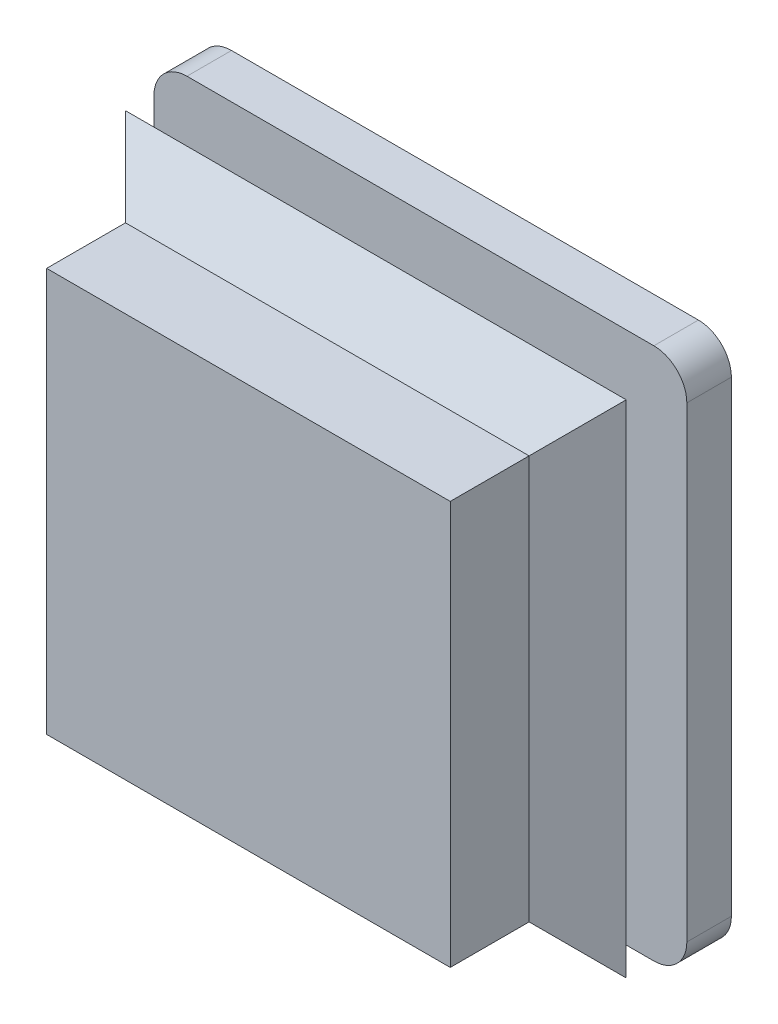
from build123d import *

# Parameters (mm, degrees)
ESQUISSE1_W        = 59.8
ESQUISSE1_H        = 59.8
BOSS_EXTRU_1_DEPTH = 5
ESQUISSE2_W        = 45.3
ESQUISSE2_H        = 45.3
BOSS_EXTRU_2_DEPTH = 24.3
CONG_1_R           = 3.7
ESQUISSE6_W        = 56.2
ESQUISSE6_H        = 56.2
BOSS_EXTRU_4_DEPTH = 10
BOSS_EXTRU_4_TAPER = 45


with BuildPart() as part:
    # Esquisse1 → Boss.-Extru.1 (new body)
    with BuildSketch(Plane.XY):
        Rectangle(ESQUISSE1_W, ESQUISSE1_H)
    extrude(amount=BOSS_EXTRU_1_DEPTH)

    # Esquisse2 → Boss.-Extru.2 (add)
    with BuildSketch(Plane.XY):
        Rectangle(ESQUISSE2_W, ESQUISSE2_H)
    extrude(amount=BOSS_EXTRU_2_DEPTH)

    # Congé1
    cong_1_edges = [part.edges().sort_by_distance(p)[0] for p in [
        (29.9, -29.9, 2.5),
        (-29.9, -29.9, 2.5),
        (-29.9, 29.9, 2.5),
        (29.9, 29.9, 2.5),
    ]]
    fillet(cong_1_edges, radius=CONG_1_R)

    # Esquisse6 → Boss.-Extru.4 (add)
    with BuildSketch(Plane.XY.offset(10)):
        Rectangle(ESQUISSE6_W, ESQUISSE6_H)
    extrude(amount=BOSS_EXTRU_4_DEPTH, taper=BOSS_EXTRU_4_TAPER)


solid = part.part
